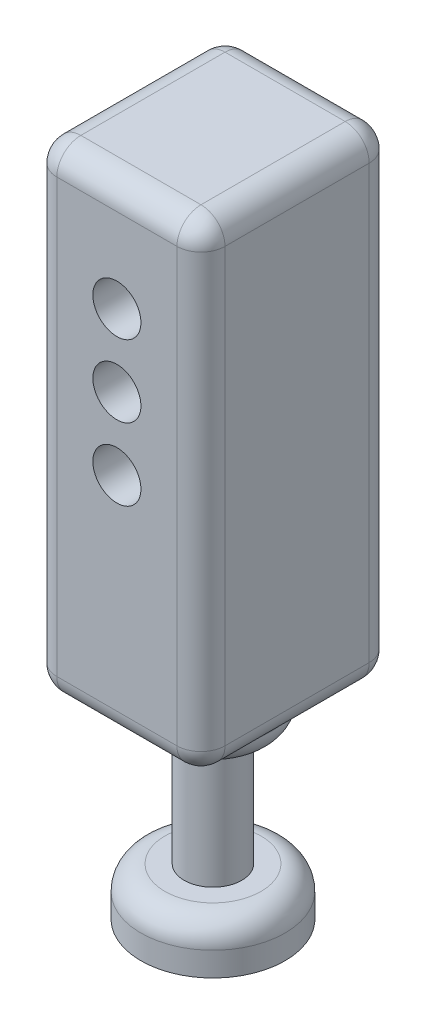
from build123d import *

# Parameters (mm, degrees)
SKETCH1_W           = 70
SKETCH1_H           = 200
BOSS_EXTRUDE1_DEPTH = 80
FILLET1_R           = 10
SKETCH2_R           = 24.442521079
BOSS_EXTRUDE2_DEPTH = 15
FILLET3_R           = 10
SKETCH3_R           = 12
BOSS_EXTRUDE3_DEPTH = 50
SKETCH4_R           = 30
BOSS_EXTRUDE4_DEPTH = 20
FILLET4_R           = 10
SKETCH5_R           = 10
CUT_EXTRUDE1_DEPTH  = 80


with BuildPart() as part:
    # Sketch1 → Boss-Extrude1 (new body)
    with BuildSketch(Plane.XY):
        with Locations((20.223475334, 1.448561813)):
            Rectangle(SKETCH1_W, SKETCH1_H)
    extrude(amount=BOSS_EXTRUDE1_DEPTH)

    # Fillet1
    fillet1_edges = [part.edges().sort_by_distance(p)[0] for p in [
        (55.223475334, 1.448561813, 80),
        (20.223475334, 101.448561813, 80),
        (-14.776524666, 1.448561813, 80),
        (20.223475334, 101.448561813, 0),
        (55.223475334, 1.448561813, 0),
        (20.223475334, -98.551438187, 0),
        (-14.776524666, 1.448561813, 0),
        (-14.776524666, 101.448561813, 40),
        (55.223475334, 101.448561813, 40),
        (55.223475334, -98.551438187, 40),
        (-14.776524666, -98.551438187, 40),
        (20.223475334, -98.551438187, 80),
    ]]
    fillet(fillet1_edges, radius=FILLET1_R)

    # Sketch2 → Boss-Extrude2 (add)
    with BuildSketch(Plane(origin=(0, -98.551438187, 0), x_dir=(-1, 0, 0), z_dir=(0, -1, 0))):
        with Locations((-20.223475334, -40)):
            Circle(SKETCH2_R)
    extrude(amount=BOSS_EXTRUDE2_DEPTH)

    # Fillet3
    fillet3_edges = [part.edges().sort_by_distance(p)[0] for p in [
        (44.665996414, -113.551438187, 40),
    ]]
    fillet(fillet3_edges, radius=FILLET3_R)

    # Sketch3 → Boss-Extrude3 (add)
    with BuildSketch(Plane.XZ.offset(113.551438187)):
        with Locations((20.19472106, 39.984491152)):
            Circle(SKETCH3_R)
    extrude(amount=BOSS_EXTRUDE3_DEPTH)

    # Sketch4 → Boss-Extrude4 (add)
    with BuildSketch(Plane(origin=(0, -163.551438187, 0), x_dir=(-1, 0, 0), z_dir=(0, -1, 0))):
        with Locations((-20.19472106, -39.984491152)):
            Circle(SKETCH4_R)
    extrude(amount=BOSS_EXTRUDE4_DEPTH)

    # Fillet4
    fillet4_edges = [part.edges().sort_by_distance(p)[0] for p in [
        (50.19472106, -163.551438187, 39.984491152),
    ]]
    fillet(fillet4_edges, radius=FILLET4_R)

    # Sketch5 → Cut-Extrude1 (cut)
    with BuildSketch(Plane.XY.offset(80)):
        with Locations((20.223475334, 56.448561813)):
            Circle(SKETCH5_R)
        with Locations((20.223475334, 26.448561813)):
            Circle(SKETCH5_R)
        with Locations((20.223475334, -3.551438187)):
            Circle(SKETCH5_R)
    extrude(amount=-CUT_EXTRUDE1_DEPTH, mode=Mode.SUBTRACT)


solid = part.part
